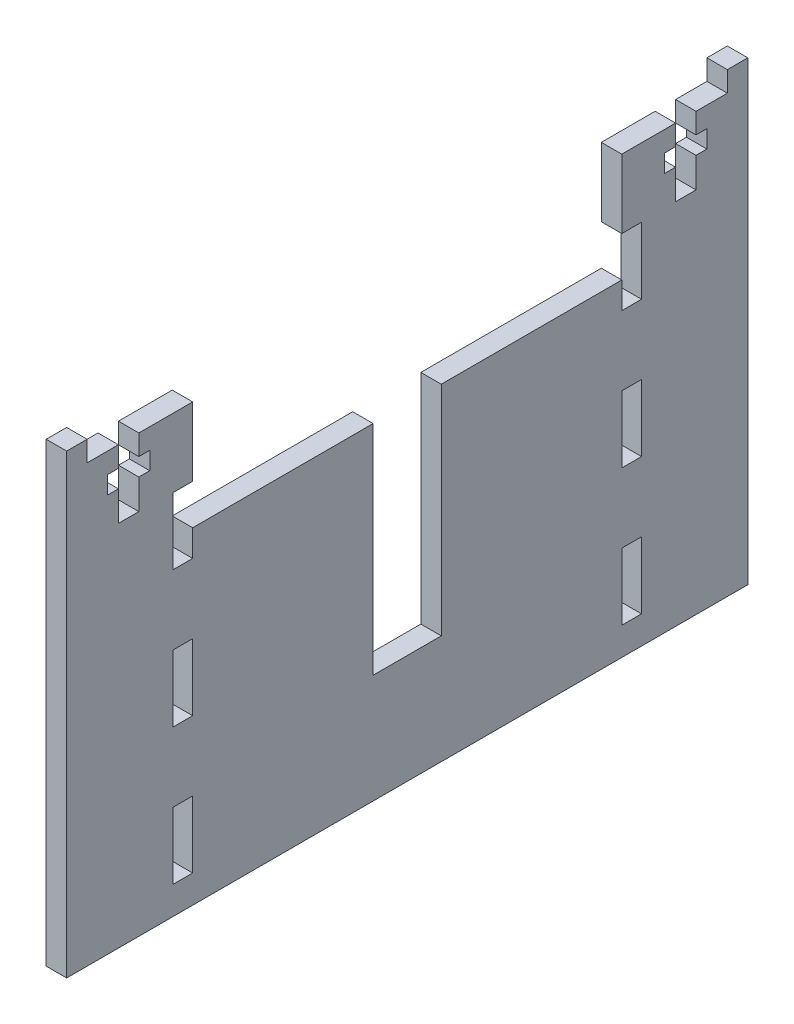
from build123d import *

# Parameters (mm, degrees)
SKETCH1_W           = 100
SKETCH1_H           = 64
BOSS_EXTRUDE1_DEPTH = 3
SKETCH2_W           = 2.9
SKETCH2_H           = 9.8
CUT_EXTRUDE1_DEPTH  = 3
CUT_EXTRUDE2_DEPTH  = 10
SKETCH5_W           = 63
SKETCH5_H           = 16
CUT_EXTRUDE3_DEPTH  = 10
SKETCH6_W           = 10
SKETCH6_H           = 32
CUT_EXTRUDE4_DEPTH  = 10
SKETCH7_W           = 3
SKETCH7_H           = 3
BOSS_EXTRUDE2_DEPTH = 3


with BuildPart() as part:
    # Sketch1 → Boss-Extrude1 (new body)
    with BuildSketch(Plane(origin=(0, 0, 0), x_dir=(0, 0, -1), z_dir=(1, 0, 0))):
        Rectangle(SKETCH1_W, SKETCH1_H)
    extrude(amount=BOSS_EXTRUDE1_DEPTH)

    # Sketch2 → Cut-Extrude1 (cut)
    with BuildSketch(Plane(origin=(3, 0, 0), x_dir=(0, 0, -1), z_dir=(1, 0, 0))):
        with Locations((-32.95, 17)):
            Rectangle(SKETCH2_W, SKETCH2_H)
        with Locations((-32.95, -3)):
            Rectangle(SKETCH2_W, SKETCH2_H)
        with Locations((-32.95, -23)):
            Rectangle(SKETCH2_W, SKETCH2_H)
        with Locations((32.95, -23)):
            Rectangle(SKETCH2_W, SKETCH2_H)
        with Locations((32.95, -3)):
            Rectangle(SKETCH2_W, SKETCH2_H)
        with Locations((32.95, 17)):
            Rectangle(SKETCH2_W, SKETCH2_H)
    extrude(amount=-CUT_EXTRUDE1_DEPTH, mode=Mode.SUBTRACT)

    # Sketch3 → Cut-Extrude2 (cut)
    with BuildSketch(Plane(origin=(3, 0, 0), x_dir=(0, 0, -1), z_dir=(1, 0, 0))):
        Polygon((-42.4, 32), (-42.4, 29), (-44, 29), (-44, 26.4), (-42.4, 26.4), (-42.4, 22), (-39.4, 22), (-39.4, 26.4), (-37.8, 26.4), (-37.8, 29), (-39.4, 29), (-39.4, 32), align=None)
    cut_extrude2 = extrude(amount=-CUT_EXTRUDE2_DEPTH, mode=Mode.SUBTRACT)

    # Mirror1: Cut-Extrude2 across plane
    add(cut_extrude2.mirror(Plane.XY), mode=Mode.SUBTRACT)

    # Sketch5 → Cut-Extrude3 (cut)
    with BuildSketch(Plane(origin=(3, 0, 0), x_dir=(0, 0, -1), z_dir=(1, 0, 0))):
        with Locations((0, 24)):
            Rectangle(SKETCH5_W, SKETCH5_H)
    extrude(amount=-CUT_EXTRUDE3_DEPTH, mode=Mode.SUBTRACT)

    # Sketch6 → Cut-Extrude4 (cut)
    with BuildSketch(Plane(origin=(3, 0, 0), x_dir=(0, 0, -1), z_dir=(1, 0, 0))):
        Rectangle(SKETCH6_W, SKETCH6_H)
    extrude(amount=-CUT_EXTRUDE4_DEPTH, mode=Mode.SUBTRACT)

    # Sketch7 → Boss-Extrude2 (add)
    with BuildSketch(Plane(origin=(3, 0, 0), x_dir=(0, 0, -1), z_dir=(1, 0, 0))):
        with Locations((-48.5, 33.5)):
            Rectangle(SKETCH7_W, SKETCH7_H)
        with Locations((48.5, 33.5)):
            Rectangle(SKETCH7_W, SKETCH7_H)
    extrude(amount=-BOSS_EXTRUDE2_DEPTH)


solid = part.part
